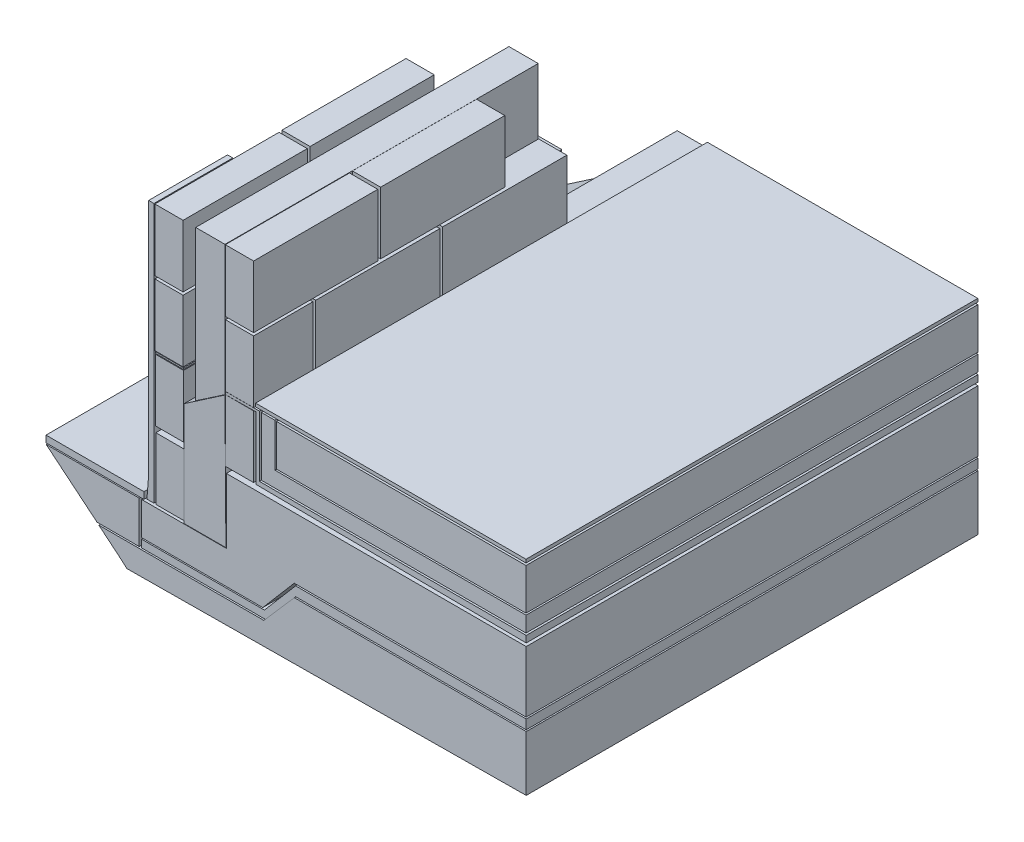
from build123d import *

# Parameters (mm, degrees)
EXTRUDE1_DEPTH    = 1601
EXTRUDE4_DEPTH    = 1601
EXTRUDE5_DEPTH    = 1601
SKETCH8_W         = 100
SKETCH8_H         = 220
EXTRUDE6_DEPTH    = 210
SKETCH9_W         = 100
SKETCH9_H         = 220
EXTRUDE7_DEPTH    = 440
EXTRUDE7_2_DEPTH  = 440
SKETCH10_W        = 100
SKETCH10_H        = 220
EXTRUDE8_DEPTH    = 210
EXTRUDE8_2_DEPTH  = 210
SKETCH11_W        = 100
SKETCH11_H        = 220
EXTRUDE9_DEPTH    = 440
EXTRUDE9_2_DEPTH  = 440
SKETCH12_W        = 440
SKETCH12_H        = 220
EXTRUDE10_DEPTH   = 100
EXTRUDE10_2_DEPTH = 100
SKETCH13_W        = 440
SKETCH13_H        = 220
EXTRUDE11_DEPTH   = 100
EXTRUDE11_2_DEPTH = 100
SKETCH14_W        = 440
SKETCH14_H        = 220
EXTRUDE12_DEPTH   = 100
SKETCH15_W        = 440
SKETCH15_H        = 220
EXTRUDE13_DEPTH   = 100
EXTRUDE13_2_DEPTH = 100
SKETCH16_W        = 440
SKETCH16_H        = 220
EXTRUDE14_DEPTH   = 100
SKETCH17_W        = 440
SKETCH17_H        = 220
SKETCH17_W_2      = 210
EXTRUDE15_DEPTH   = 100
EXTRUDE19_DEPTH   = 1601
EXTRUDE20_DEPTH   = 1601
EXTRUDE22_DEPTH   = 1601
SKETCH22_W        = 884.263168632
SKETCH22_H        = 146.261297649
EXTRUDE23_DEPTH   = 1601
SKETCH23_W        = 99.674406251
SKETCH23_H        = 5.258601769
EXTRUDE24_DEPTH   = 1340
EXTRUDE25_DEPTH   = 1340
EXTRUDE26_DEPTH   = 1110
EXTRUDE29_DEPTH   = 559
EXTRUDE33_DEPTH   = 21.5
SKETCH31_W        = 347.013000092
SKETCH31_H        = 23.832289604
EXTRUDE34_DEPTH   = 1601
SKETCH32_W        = 958.272742481
SKETCH32_H        = 11.668121191
EXTRUDE35_DEPTH   = 1601


with BuildPart() as part:
    # Sketch1 → Extrude1 (new body)
    with BuildSketch(Plane.XY):
        Polygon((0, 0), (26.126166607, -22.821644295), (1435.806285755, -11.410822148), (1440.999178225, -11.410822148), (1440.999178225, 184.686840055), (1435.806285755, 184.686840055), (619.492761702, 184.686840055), (511.40229267, 60.945116364), (-73.68967213, 60.945116364), align=None)
    extrude(amount=-EXTRUDE1_DEPTH)


with BuildPart() as body_2:
    # Sketch6 → Extrude4 (new body)
    with BuildSketch(Plane.XY):
        Polygon((1440.999178225, 228.887823637), (1440.999178225, 445.503329066), (378.366862189, 445.503329066), (378.366862189, 215.503329066), (78.366862189, 215.503329066), (78.366862189, 98.317679487), (507.433993659, 98.317679487), (618.946522337, 228.887823637), align=None)
    extrude(amount=-EXTRUDE4_DEPTH)


with BuildPart() as body_3:
    # Sketch7 → Extrude5 (new body)
    with BuildSketch(Plane.XY):
        Polygon((78.366862189, 93.568960642), (513.296590599, 93.568960642), (624.055092865, 223.2374511), (1440.999178225, 223.2374511), (1440.999178225, 190.019217536), (624.055092865, 190.019217536), (518.763716146, 66.751264304), (78.366862189, 66.751264304), align=None)
    extrude(amount=-EXTRUDE5_DEPTH)


with BuildPart() as body_4:
    # Sketch8 → Extrude6 (new body)
    with BuildSketch(Plane.XY):
        with Locations((178.366862189, 335.503329066)):
            Rectangle(SKETCH8_W, SKETCH8_H)
    extrude(amount=-EXTRUDE6_DEPTH)


with BuildPart() as body_5:
    # Sketch9 → Extrude7 (new body)
    with BuildSketch(Plane.XY):
        with Locations((176.718120552, 575.69688605)):
            Rectangle(SKETCH9_W, SKETCH9_H)
    extrude(amount=-EXTRUDE7_DEPTH)


with BuildPart() as body_6:
    # Sketch9 → Extrude7 2 (new body)
    with BuildSketch(Plane.XY):
        with Locations((425.06472505, 575.69688605)):
            Rectangle(SKETCH9_W, SKETCH9_H)
    extrude(amount=-EXTRUDE7_2_DEPTH)


with BuildPart() as body_7:
    # Sketch10 → Extrude8 (new body)
    with BuildSketch(Plane.XY):
        with Locations((175.151920936, 805.69688605)):
            Rectangle(SKETCH10_W, SKETCH10_H)
    extrude(amount=-EXTRUDE8_DEPTH)


with BuildPart() as body_8:
    # Sketch10 → Extrude8 2 (new body)
    with BuildSketch(Plane.XY):
        with Locations((425.06472505, 805.69688605)):
            Rectangle(SKETCH10_W, SKETCH10_H)
    extrude(amount=-EXTRUDE8_2_DEPTH)



with BuildPart() as body_9:
    # Sketch11 → Extrude9 (new body)
    with BuildSketch(Plane.XY):
        with Locations((175.151920936, 1035.69688605)):
            Rectangle(SKETCH11_W, SKETCH11_H)
    extrude(amount=-EXTRUDE9_DEPTH)


with BuildPart() as body_10:
    # Sketch11 → Extrude9 2 (new body)
    with BuildSketch(Plane.XY):
        with Locations((424.775984789, 1035.69688605)):
            Rectangle(SKETCH11_W, SKETCH11_H)
    extrude(amount=-EXTRUDE9_2_DEPTH)


with BuildPart() as body_11:
    # Sketch12 → Extrude10 (new body)
    with BuildSketch(Plane.ZY.offset(-128.366862189)):
        with Locations((-440, 335.503329066)):
            Rectangle(SKETCH12_W, SKETCH12_H)
    extrude(amount=-EXTRUDE10_DEPTH)


with BuildPart() as body_12:
    # Sketch12 → Extrude10 2 (new body)
    with BuildSketch(Plane.ZY.offset(-128.366862189)):
        with Locations((-890, 335.503329066)):
            Rectangle(SKETCH12_W, SKETCH12_H)
    extrude(amount=-EXTRUDE10_2_DEPTH)


with BuildPart() as body_13:
    # Sketch13 → Extrude11 (new body)
    with BuildSketch(Plane.ZY.offset(-126.718120552)):
        with Locations((-670, 575.984165196)):
            Rectangle(SKETCH13_W, SKETCH13_H)
    extrude(amount=-EXTRUDE11_DEPTH)


with BuildPart() as body_14:
    # Sketch13 → Extrude11 2 (new body)
    with BuildSketch(Plane.ZY.offset(-126.718120552)):
        with Locations((-1120, 575.69688605)):
            Rectangle(SKETCH13_W, SKETCH13_H)
    extrude(amount=-EXTRUDE11_2_DEPTH)


with BuildPart() as body_15:
    # Sketch14 → Extrude12 (new body)
    with BuildSketch(Plane.ZY.offset(-128.366862189)):
        with Locations((-1340, 335.503329066)):
            Rectangle(SKETCH14_W, SKETCH14_H)
    extrude(amount=-EXTRUDE12_DEPTH)


with BuildPart() as body_16:
    # Sketch15 → Extrude13 (new body)
    with BuildSketch(Plane.ZY.offset(-125.151920936)):
        with Locations((-440, 805.273961595)):
            Rectangle(SKETCH15_W, SKETCH15_H)
    extrude(amount=-EXTRUDE13_DEPTH)


with BuildPart() as body_17:
    # Sketch15 → Extrude13 2 (new body)
    with BuildSketch(Plane.ZY.offset(-125.151920936)):
        with Locations((-890, 805.502586108)):
            Rectangle(SKETCH15_W, SKETCH15_H)
    extrude(amount=-EXTRUDE13_2_DEPTH)


with BuildPart() as body_18:
    # Sketch16 → Extrude14 (new body)
    with BuildSketch(Plane.ZY.offset(-125.151920936)):
        with Locations((-670, 1037.20109454)):
            Rectangle(SKETCH16_W, SKETCH16_H)
    extrude(amount=-EXTRUDE14_DEPTH)


with BuildPart() as body_8_1:
    add(body_8.part)

    add(body_10.part)  # Extrude15 merges body 10
    # Sketch17 → Extrude15 (add)
    with BuildSketch(Plane(origin=(475.06472505, 0, 0), x_dir=(0, 0, -1), z_dir=(1, 0, 0))):
        with Locations((670, 575.984165196)):
            Rectangle(SKETCH17_W, SKETCH17_H)
        with Locations((1120, 575.69688605)):
            Rectangle(SKETCH17_W, SKETCH17_H)
        with Locations((890, 805.502586108)):
            Rectangle(SKETCH17_W, SKETCH17_H)
        with Locations((440, 805.273961595)):
            Rectangle(SKETCH17_W, SKETCH17_H)
        with Locations((105, 805.69688605)):
            Rectangle(SKETCH17_W_2, SKETCH17_H)
        with Locations((220, 1035.69688605)):
            Rectangle(SKETCH17_W, SKETCH17_H)
        with Locations((670, 1037.20109454)):
            Rectangle(SKETCH17_W, SKETCH17_H)
    extrude(amount=-EXTRUDE15_DEPTH)


with BuildPart() as body_18_2:
    # Sketch18 → Extrude19 (new body)
    with BuildSketch(Plane.XY):
        Polygon((69.756142348, 66.751264304), (69.756142348, 215.263106623), (-260.036513682, 215.263106623), (-79.798750842, 66.751264304), align=None)
    extrude(amount=-EXTRUDE19_DEPTH)


with BuildPart() as body_19:
    # Sketch19 → Extrude20 (new body)
    with BuildSketch(Plane.XY):
        Polygon((1440.999178225, 456.525658245), (483.087511584, 464.366295024), (483.087511584, 626.754565986), (483.087511584, 686.95114936), (375.06472505, 685.984165196), (375.06472505, 695.273961595), (495.420797986, 695.273961595), (495.420797986, 626.754565986), (495.420797986, 479.782903027), (1440.999178225, 479.782903027), align=None)
    extrude(amount=-EXTRUDE20_DEPTH)


with BuildPart() as body_20:
    # Sketch21 → Extrude22 (new body)
    with BuildSketch(Plane.XY):
        Polygon((502.236963351, 694.753200842), (502.236963351, 486.590571965), (1440.32757717, 486.590571965), (1440.32757717, 541.58159727), (550.44168087, 541.58159727), (550.44168087, 694.753200842), align=None)
    extrude(amount=-EXTRUDE22_DEPTH)


with BuildPart() as body_21:
    # Sketch22 → Extrude23 (new body)
    with BuildSketch(Plane.XY):
        with Locations((998.195992854, 620.749786062)):
            Rectangle(SKETCH22_W, SKETCH22_H)
    extrude(amount=-EXTRUDE23_DEPTH)


with BuildPart() as body_22:
    # Sketch23 → Extrude24 (new body)
    with BuildSketch(Plane.XY):
        with Locations((176.798302736, 691.185249349)):
            Rectangle(SKETCH23_W, SKETCH23_H)
    extrude(amount=-EXTRUDE24_DEPTH)


with BuildPart() as body_23:
    # Sketch24 → Extrude25 (new body)
    with BuildSketch(Plane.XY):
        Polygon((373.469164073, 683.693778585), (376.864380763, 216.962015435), (229.038895605, 216.962015435), (229.038895605, 585.024282596), align=None)
    extrude(amount=-EXTRUDE25_DEPTH)


with BuildPart() as body_24:
    # Sketch25 → Extrude26 (new body)
    with BuildSketch(Plane.XY):
        Polygon((373.616807305, 684.857629772), (373.616807305, 1146.160611186), (269.798634149, 1146.160611186), (269.798634149, 614.142238669), align=None)
    extrude(amount=-EXTRUDE26_DEPTH)


with BuildPart() as body_25:
    # Sketch27 → Extrude29 (new body)
    with BuildSketch(Plane.XY):
        Polygon((121.976587479, 1145.770249408), (121.976587479, 225.923663458), (96.972759783, 225.923663458), (103.220774748, 304.023850517), (103.220774748, 1145.770249408), align=None)
    extrude(amount=-EXTRUDE29_DEPTH)

    # Sketch30 → Extrude33 (cut, symmetric)
    with BuildSketch(Plane.ZY.offset(-103.220774748)):
        with BuildLine():
            Line((-559, 1145.770249408), (-279.5, 1145.770249408))
            add(Edge.make_bspline(
                [(-279.5, 1145.770249408), (-3.117723873, 751.986061383), (-620.592415463, 618.202311694), (-470.849560276, 225.923663458)],
                knots=[0, 0, 0, 0, 1, 1, 1, 1], degree=3))
            Line((-470.849560276, 225.923663458), (-559, 225.923663458))
            Line((-559, 225.923663458), (-559, 1145.770249408))
        make_face()
    extrude(amount=EXTRUDE33_DEPTH, both=True, mode=Mode.SUBTRACT)


with BuildPart() as body_26:
    # Sketch31 → Extrude34 (new body)
    with BuildSketch(Plane.XY):
        with Locations((-87.122391198, 231.725409786)):
            Rectangle(SKETCH31_W, SKETCH31_H)
    extrude(amount=-EXTRUDE34_DEPTH)


with BuildPart() as body_27:
    # Sketch32 → Extrude35 (new body)
    with BuildSketch(Plane.XY):
        with Locations((961.19120593, 707.346853324)):
            Rectangle(SKETCH32_W, SKETCH32_H)
    extrude(amount=-EXTRUDE35_DEPTH)


solid = Compound([part.part, body_2.part, body_3.part, body_4.part, body_5.part, body_6.part, body_7.part, body_9.part, body_11.part, body_12.part, body_13.part, body_14.part, body_15.part, body_16.part, body_17.part, body_18.part, body_8_1.part, body_18_2.part, body_19.part, body_20.part, body_21.part, body_22.part, body_23.part, body_24.part, body_25.part, body_26.part, body_27.part])
